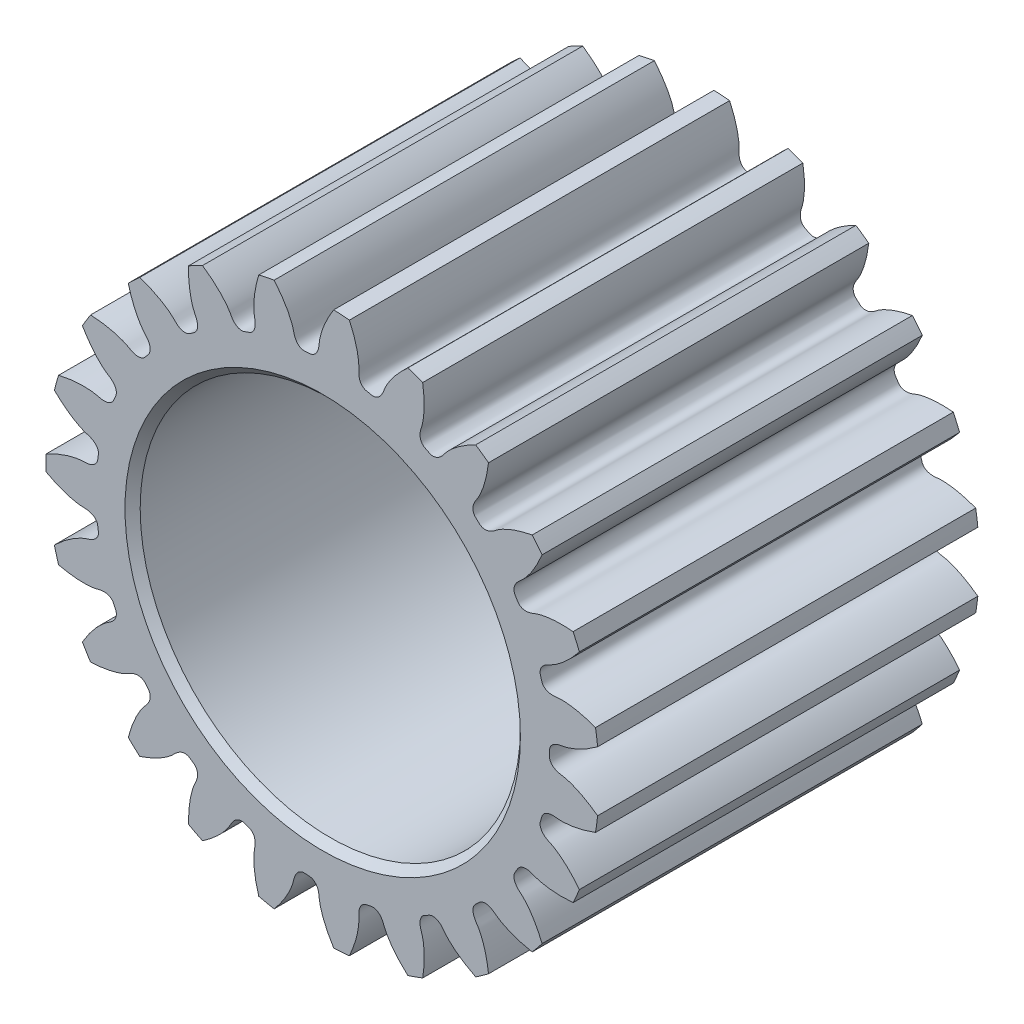
from build123d import *

# Parameters (mm, degrees)
SKETCHREVOLVEPLANET_REVOLVING_FOLLOWER02_W     = 12.7
SKETCHREVOLVEPLANET_REVOLVING_FOLLOWER02_H     = 9.237142915
TOOTHEXTRUDECUTPLANET_REVOLVING_FOLLOWER_DEPTH = 6.35
PATTERNPLANET_REVOLVING_FOLLOWER02_COUNT       = 23


with BuildPart() as part:
    # SketchRevolvePlanet_Revolving_Follower02 → Planet_Revolving_Follower02 (revolve)
    with BuildSketch(Plane(origin=(0, 0, 0), x_dir=(0, 0, -1), z_dir=(1, 0, 0))):
        with Locations((0, 4.618571457)):
            Rectangle(SKETCHREVOLVEPLANET_REVOLVING_FOLLOWER02_W, SKETCHREVOLVEPLANET_REVOLVING_FOLLOWER02_H)
    revolve(axis=Axis((0, 0, 0), (0, 0, -1)))

    # SketchToothPlanet_Revolving_Follower02 → ToothExtrudeCutPlanet_Revolving_Follower (cut, symmetric)
    with BuildSketch(Plane.XY):
        with BuildLine():
            ThreePointArc((9.217538207, 1.02262521), (9.274091487, 0), (9.217538207, -1.02262521))
            add(Edge.make_bspline(
                [(9.217538207, -1.02262521), (9.114515057, -0.945323682), (8.976795886, -0.850414153), (8.802731173, -0.74583247), (8.708625109, -0.693005596), (8.619171317, -0.646204237), (8.534638245, -0.605105121), (8.455279098, -0.569374283), (8.381331659, -0.538667648), (8.313017647, -0.512633183), (8.250543239, -0.490906238), (8.194096034, -0.473127273), (8.143853392, -0.458888682), (8.09995555, -0.44790159), (8.032784448, -0.432796248), (7.972274976, -0.425984524), (7.91857449, -0.414698321), (7.898445765, -0.409975716), (7.878743217, -0.404807834), (7.859446029, -0.399185044), (7.840532592, -0.393081474), (7.821978764, -0.386467151), (7.803758567, -0.379302984), (7.785844539, -0.371539878), (7.768208662, -0.363116325), (7.750823861, -0.353955953), (7.733666418, -0.34396468), (7.716719709, -0.333027746), (7.699979772, -0.321006947), (7.683463332, -0.307738766), (7.667218898, -0.293034609), (7.65134127, -0.276685054), (7.635989029, -0.258470855), (7.621402861, -0.238184046), (7.607920293, -0.215661975), (7.595977449, -0.190835249), (7.586092591, -0.163781884), (7.578802143, -0.134783001), (7.574908085, -0.106341653), (7.573219004, -0.061252336), (7.575396817, 0), (7.573219004, 0.061252336), (7.574908085, 0.106341653), (7.578802143, 0.134783001), (7.586092591, 0.163781884), (7.595977449, 0.190835249), (7.607920293, 0.215661975), (7.621402861, 0.238184046), (7.635989029, 0.258470855), (7.65134127, 0.276685054), (7.667218898, 0.293034609), (7.683463332, 0.307738766), (7.699979772, 0.321006947), (7.716719709, 0.333027746), (7.733666418, 0.34396468), (7.750823861, 0.353955953), (7.768208662, 0.363116325), (7.785844539, 0.371539878), (7.803758567, 0.379302984), (7.821978764, 0.386467151), (7.840532592, 0.393081474), (7.859446029, 0.399185044), (7.878743217, 0.404807834), (7.898445765, 0.409975716), (7.91857449, 0.414698321), (7.972274976, 0.425984524), (8.032784448, 0.432796248), (8.09995555, 0.44790159), (8.143853392, 0.458888682), (8.194096034, 0.473127273), (8.250543239, 0.490906238), (8.313017647, 0.512633183), (8.381331659, 0.538667648), (8.455279098, 0.569374283), (8.534638245, 0.605105121), (8.619171317, 0.646204237), (8.708625109, 0.693005596), (8.802731173, 0.74583247), (8.976795886, 0.850414153), (9.114515057, 0.945323682), (9.217538207, 1.02262521)],
                knots=[0, 0, 0, 0, 0.094201823, 0.122209858, 0.148520436, 0.173133558, 0.196049223, 0.217267431, 0.236788183, 0.254611478, 0.270737317, 0.285165699, 0.297896624, 0.308930093, 0.318266106, 0.348239691, 0.35336124, 0.358399485, 0.363362459, 0.36825932, 0.373100535, 0.377898093, 0.38266574, 0.387419255, 0.392176747, 0.396958971, 0.401789634, 0.406695665, 0.411707358, 0.416858296, 0.422184875, 0.42772519, 0.433516989, 0.439594357, 0.44598294, 0.452693853, 0.459717068, 0.467015988, 0.474525558, 0.480668128, 0.5, 0.519331872, 0.525474442, 0.532984012, 0.540282932, 0.547306147, 0.55401706, 0.560405643, 0.566483011, 0.57227481, 0.577815125, 0.583141704, 0.588292642, 0.593304335, 0.598210366, 0.603041029, 0.607823253, 0.612580745, 0.61733426, 0.622101907, 0.626899465, 0.63174068, 0.636637541, 0.641600515, 0.64663876, 0.651760309, 0.681733894, 0.691069907, 0.702103376, 0.714834301, 0.729262683, 0.745388522, 0.763211817, 0.782732569, 0.803950777, 0.826866442, 0.851479564, 0.877790142, 0.905798177, 1, 1, 1, 1], degree=3))
        make_face()
    toothextrudecutplanet_revolving_follower = extrude(amount=TOOTHEXTRUDECUTPLANET_REVOLVING_FOLLOWER_DEPTH, both=True, mode=Mode.SUBTRACT)

    # PatternPlanet_Revolving_Follower02: ToothExtrudeCutPlanet_Revolving_Follower ×23 about axis
    patternplanet_revolving_follower02_axis = Axis((0, 0, 55), (0, 0, -1))
    for i in range(1, PATTERNPLANET_REVOLVING_FOLLOWER02_COUNT):
        add(toothextrudecutplanet_revolving_follower.rotate(patternplanet_revolving_follower02_axis, i * 360 / PATTERNPLANET_REVOLVING_FOLLOWER02_COUNT), mode=Mode.SUBTRACT)

    # BoreRevolveSketch → BoreRevolveCut (revolve, cut)
    with BuildSketch(Plane(origin=(0, 0, 0), x_dir=(0, 0, -1), z_dir=(1, 0, 0))):
        Polygon((-6.35, 0), (6.35, 0), (6.35, 6.604), (6.096, 6.35), (-6.096, 6.35), (-6.35, 6.604), align=None)
    revolve(axis=Axis((0, 0, 0), (0, 0, -1)), mode=Mode.SUBTRACT)


solid = part.part
